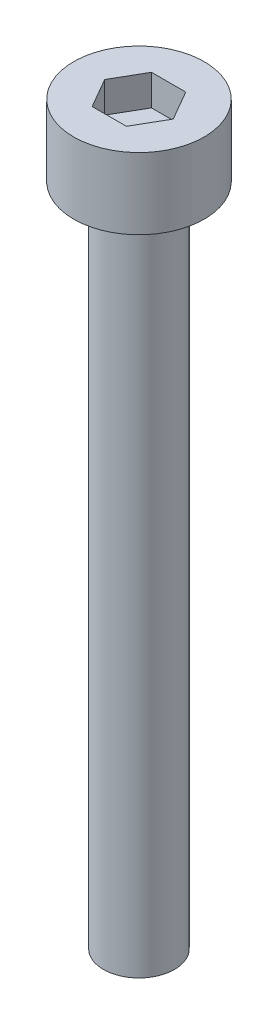
from build123d import *

# Parameters (mm, degrees)
SKETCH_1_R            = 2.75
EXTRUDE_248_DEPTH     = 3
CUT_EXTRUDE_378_DEPTH = 1.3
SKETCH_3_R            = 1.5
EXTRUDE_479_DEPTH     = 28


with BuildPart() as part:
    # 草图1 → Extrude 248 (new body)
    with BuildSketch(Plane(origin=(0, 0, 0), x_dir=(1, 0, 0), z_dir=(0, 1, 0))):
        Circle(SKETCH_1_R)
    extrude(amount=EXTRUDE_248_DEPTH)

    # 草图2 → Cut-Extrude 378 (cut)
    with BuildSketch(Plane(origin=(0, 3, 0), x_dir=(1, 0, 0), z_dir=(0, 1, 0))):
        Polygon((1.443375673, 0), (0.721687836, 1.25), (-0.721687836, 1.25), (-1.443375673, 0), (-0.721687836, -1.25), (0.721687836, -1.25), align=None)
    extrude(amount=-CUT_EXTRUDE_378_DEPTH, mode=Mode.SUBTRACT)

    # 草图3 → Extrude 479 (add)
    with BuildSketch(Plane.XZ):
        Circle(SKETCH_3_R)
    extrude(amount=EXTRUDE_479_DEPTH)


solid = part.part
